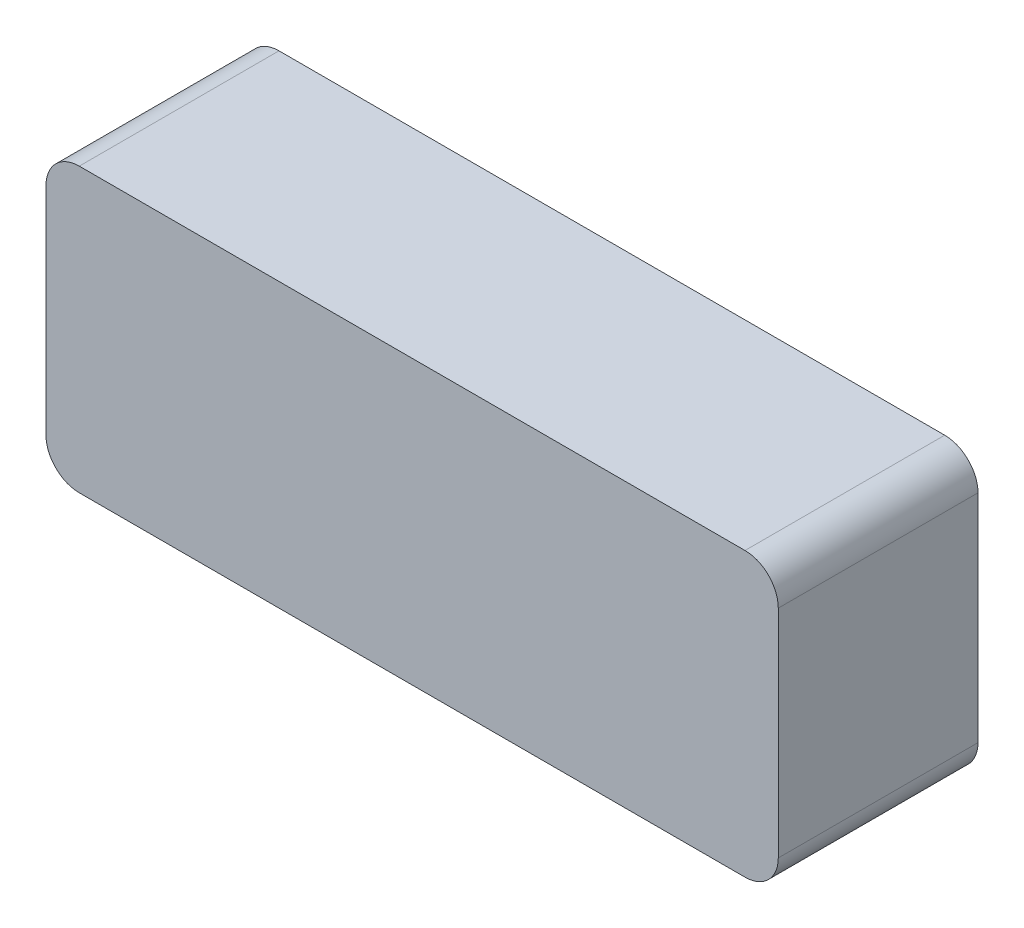
from build123d import *

# Parameters (mm, degrees)
ESBO_O1_W                = 44
ESBO_O1_H                = 17
RESSALTO_EXTRUS_O1_DEPTH = 12
FILETE1_R                = 2


with BuildPart() as part:
    # Esboço1 → Ressalto-extrusão1 (new body)
    with BuildSketch(Plane.XY):
        with Locations((22, -8.5)):
            Rectangle(ESBO_O1_W, ESBO_O1_H)
    extrude(amount=RESSALTO_EXTRUS_O1_DEPTH)

    # Filete1
    filete1_edges = [part.edges().sort_by_distance(p)[0] for p in [
        (0, 0, 6),
        (44, 0, 6),
        (44, -17, 6),
        (0, -17, 6),
    ]]
    fillet(filete1_edges, radius=FILETE1_R)


solid = part.part
